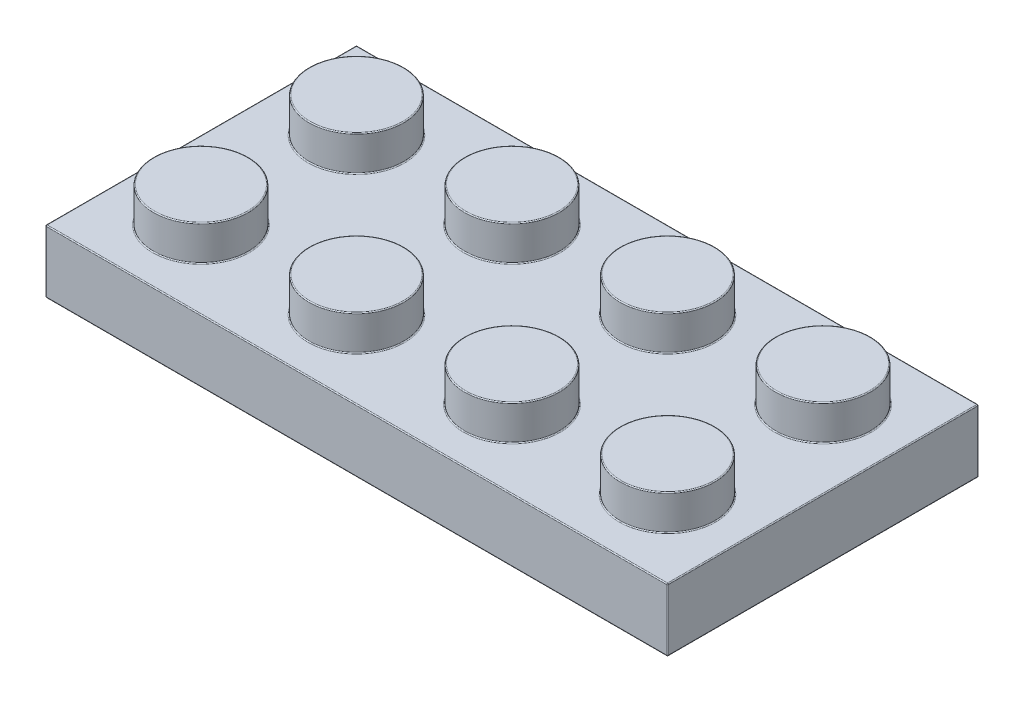
from build123d import *

# Parameters (mm, degrees)
SKETCH1_W                 = 7.96
SKETCH1_H                 = 7.96
EXTRUDE1_DEPTH            = 3.22
SKETCH2_R                 = 2.425
EXTRUDE2_DEPTH            = 1.8
LPATTERN1_COUNT           = 4
LPATTERN1_PITCH           = 7.96
LPATTERN2_COUNT           = 2
LPATTERN2_PITCH           = 7.96
LPATTERN2_COPY_1_SKETCH_W = 7.96
LPATTERN2_COPY_1_SKETCH_H = 7.96
LPATTERN2_COPY_1_DEPTH    = 3.22
LPATTERN2_COPY_2_SKETCH_W = 7.96
LPATTERN2_COPY_2_SKETCH_H = 7.96
LPATTERN2_COPY_2_DEPTH    = 3.22
LPATTERN2_COPY_3_SKETCH_W = 7.96
LPATTERN2_COPY_3_SKETCH_H = 7.96
LPATTERN2_COPY_3_DEPTH    = 3.22
LPATTERN2_COPY_4_SKETCH_R = 2.425
LPATTERN2_COPY_4_DEPTH    = 1.8
LPATTERN2_COPY_5_SKETCH_R = 2.425
LPATTERN2_COPY_5_DEPTH    = 1.8
LPATTERN2_COPY_6_SKETCH_R = 2.425
LPATTERN2_COPY_6_DEPTH    = 1.8
SHELL1_T                  = -1.55
SKETCH3_W                 = 28.74
SKETCH3_H                 = 12.82
EXTRUDE3_DEPTH            = 0.14
SKETCH4_R                 = 3.23
SKETCH4_R_2               = 2.37
EXTRUDE4_DEPTH            = 1.81
FILLET1_R                 = 0.05


with BuildPart() as part:
    # Sketch1 → Extrude1 (new body)
    with BuildSketch(Plane(origin=(0, 0, 0), x_dir=(1, 0, 0), z_dir=(0, 1, 0))):
        Rectangle(SKETCH1_W, SKETCH1_H)
    extrude1 = extrude(amount=EXTRUDE1_DEPTH)

    # Sketch2 → Extrude2 (add)
    with BuildSketch(Plane(origin=(0, 3.22, 0), x_dir=(1, 0, 0), z_dir=(0, 1, 0))):
        Circle(SKETCH2_R)
    extrude2 = extrude(amount=EXTRUDE2_DEPTH)

    # LPattern1: Extrude1, Extrude2 ×4
    with Locations(*[(i * LPATTERN1_PITCH, 0, 0) for i in range(1, LPATTERN1_COUNT)]):
        add(extrude1)
        add(extrude2)

    # LPattern2: Extrude1, Extrude2 ×2
    with Locations(*[(0, 0, -i * LPATTERN2_PITCH) for i in range(1, LPATTERN2_COUNT)]):
        add(extrude1)
        add(extrude2)

    # LPattern2 copy 1 sketch → LPattern2 copy 1 (add)
    with BuildSketch(Plane(origin=(7.96, 0, -7.96), x_dir=(1, 0, 0), z_dir=(0, 1, 0))):
        Rectangle(LPATTERN2_COPY_1_SKETCH_W, LPATTERN2_COPY_1_SKETCH_H)
    extrude(amount=LPATTERN2_COPY_1_DEPTH)

    # LPattern2 copy 2 sketch → LPattern2 copy 2 (add)
    with BuildSketch(Plane(origin=(15.92, 0, -7.96), x_dir=(1, 0, 0), z_dir=(0, 1, 0))):
        Rectangle(LPATTERN2_COPY_2_SKETCH_W, LPATTERN2_COPY_2_SKETCH_H)
    extrude(amount=LPATTERN2_COPY_2_DEPTH)

    # LPattern2 copy 3 sketch → LPattern2 copy 3 (add)
    with BuildSketch(Plane(origin=(23.88, 0, -7.96), x_dir=(1, 0, 0), z_dir=(0, 1, 0))):
        Rectangle(LPATTERN2_COPY_3_SKETCH_W, LPATTERN2_COPY_3_SKETCH_H)
    extrude(amount=LPATTERN2_COPY_3_DEPTH)

    # LPattern2 copy 4 sketch → LPattern2 copy 4 (add)
    with BuildSketch(Plane(origin=(7.96, 3.22, -7.96), x_dir=(1, 0, 0), z_dir=(0, 1, 0))):
        Circle(LPATTERN2_COPY_4_SKETCH_R)
    extrude(amount=LPATTERN2_COPY_4_DEPTH)

    # LPattern2 copy 5 sketch → LPattern2 copy 5 (add)
    with BuildSketch(Plane(origin=(15.92, 3.22, -7.96), x_dir=(1, 0, 0), z_dir=(0, 1, 0))):
        Circle(LPATTERN2_COPY_5_SKETCH_R)
    extrude(amount=LPATTERN2_COPY_5_DEPTH)

    # LPattern2 copy 6 sketch → LPattern2 copy 6 (add)
    with BuildSketch(Plane(origin=(23.88, 3.22, -7.96), x_dir=(1, 0, 0), z_dir=(0, 1, 0))):
        Circle(LPATTERN2_COPY_6_SKETCH_R)
    extrude(amount=LPATTERN2_COPY_6_DEPTH)

    # Shell1
    shell1_openings = [part.faces().sort_by_distance(p)[0] for p in [
        (11.94, 0, -3.98),
    ]]
    offset(amount=SHELL1_T, openings=shell1_openings, kind=Kind.INTERSECTION)

    # Sketch3 → Extrude3 (cut)
    with BuildSketch(Plane.XZ.offset(-1.67)):
        with Locations((11.94, -3.98)):
            Rectangle(SKETCH3_W, SKETCH3_H)
    extrude(amount=-EXTRUDE3_DEPTH, mode=Mode.SUBTRACT)

    # Sketch4 → Extrude4 (add)
    with BuildSketch(Plane.XZ.offset(-1.81)):
        with Locations((3.98, -3.98)):
            Circle(SKETCH4_R)
        with Locations((3.98, -3.98)):
            Circle(SKETCH4_R_2, mode=Mode.SUBTRACT)
        with Locations((11.94, -3.98)):
            Circle(SKETCH4_R)
        with Locations((11.94, -3.98)):
            Circle(SKETCH4_R_2, mode=Mode.SUBTRACT)
        with Locations((19.9, -3.98)):
            Circle(SKETCH4_R)
        with Locations((19.9, -3.98)):
            Circle(SKETCH4_R_2, mode=Mode.SUBTRACT)
    extrude(amount=EXTRUDE4_DEPTH)

    # Fillet1
    fillet1_edges = [part.edges().sort_by_distance(p)[0] for p in [
        (-3.98, 3.22, -3.98),
        (0.75, 1.81, -3.98),
        (1.61, 1.81, -3.98),
        (0.75, 0, -3.98),
        (1.61, 0, -3.98),
        (11.94, 3.22, 3.98),
        (8.71, 1.81, -3.98),
        (9.57, 1.81, -3.98),
        (8.71, 0, -3.98),
        (9.57, 0, -3.98),
        (16.67, 1.81, -3.98),
        (-2.425, 3.22, 0),
        (17.53, 1.81, -3.98),
        (16.67, 0, -3.98),
        (17.53, 0, -3.98),
        (-2.425, 5.02, 0),
        (27.86, 3.22, -3.98),
        (27.86, 0, -3.98),
        (27.86, 1.61, 3.98),
        (5.535, 3.22, 0),
        (5.535, 5.02, 0),
        (13.495, 3.22, 0),
        (13.495, 5.02, 0),
        (21.455, 3.22, 0),
        (21.455, 5.02, 0),
        (11.94, 0, -11.94),
        (27.86, 1.61, -11.94),
        (-3.98, 1.61, -11.94),
        (11.94, 3.22, -11.94),
        (11.94, 0, 3.98),
        (-3.98, 0, -3.98),
        (-2.425, 3.22, -7.96),
        (-2.425, 5.02, -7.96),
        (5.535, 3.22, -7.96),
        (5.535, 5.02, -7.96),
        (13.495, 3.22, -7.96),
        (13.495, 5.02, -7.96),
        (21.455, 3.22, -7.96),
        (21.455, 5.02, -7.96),
        (-2.43, 0, -3.98),
        (-2.43, 0.905, -10.39),
        (11.94, 0, 2.43),
        (-2.43, 0.905, 2.43),
        (-0.875, 3.47, 0),
        (26.31, 0, -3.98),
        (26.31, 0.905, 2.43),
        (7.085, 3.47, 0),
        (15.045, 3.47, 0),
        (23.005, 3.47, 0),
        (11.94, 0, -10.39),
        (26.31, 0.905, -10.39),
        (-0.875, 3.47, -7.96),
        (7.085, 3.47, -7.96),
        (15.045, 3.47, -7.96),
        (23.005, 3.47, -7.96),
        (-3.98, 1.61, 3.98),
        (-0.875, 1.81, 0),
        (7.085, 1.81, 0),
        (15.045, 1.81, 0),
        (23.005, 1.81, 0),
        (-0.875, 1.81, -7.96),
        (7.085, 1.81, -7.96),
        (15.045, 1.81, -7.96),
        (23.005, 1.81, -7.96),
        (11.94, 1.81, 2.43),
        (26.31, 1.81, -3.98),
        (11.94, 1.81, -10.39),
        (-2.43, 1.81, -3.98),
    ]]
    fillet(fillet1_edges, radius=FILLET1_R)


solid = part.part
